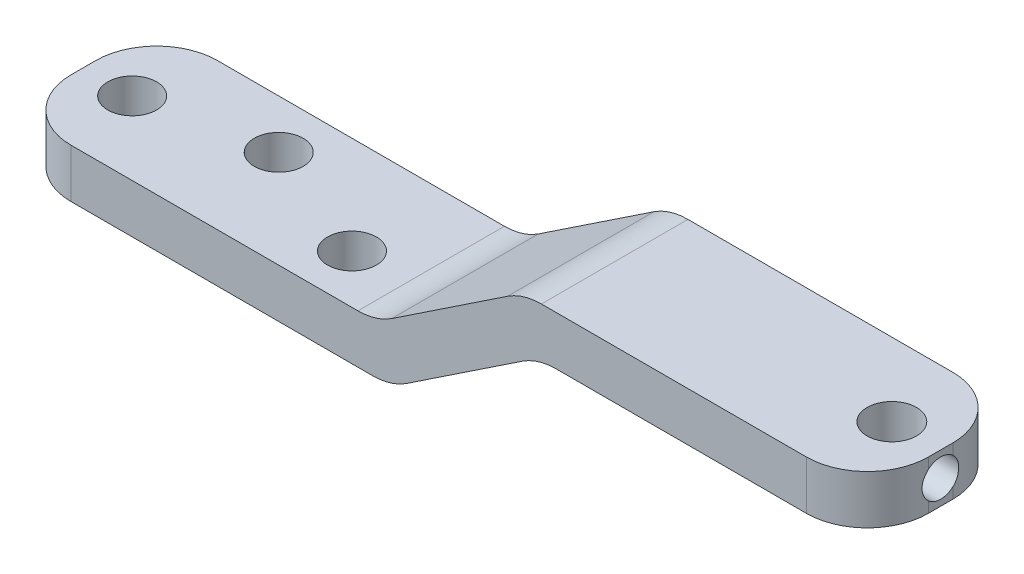
from build123d import *

# Parameters (mm, degrees)
BOSS_EXTRUDE1_DEPTH        = 6
SKETCH2_R                  = 2.025
CUT_EXTRUDE1_DEPTH         = 68.55671766
SKETCH3_R                  = 2
CUT_EXTRUDE2_DEPTH         = 67.962004906
FILLET1_R                  = 5
M3X0_5_TAPPED_HOLE1_REACH  = 72.92
M3X0_5_TAPPED_HOLE1_BORE_R = 1.5


with BuildPart() as part:
    # Sketch1 → Boss-Extrude1 (new, symmetric)
    with BuildSketch(Plane.XY):
        Polygon((4, 0), (-23, 0), (-35, -8), (-66.211102551, -8), (-66.211102551, -4), (-36.211102551, -4), (-24.211102551, 4), (4, 4), align=None)
    extrude(amount=BOSS_EXTRUDE1_DEPTH, both=True)

    # Sketch2 → Cut-Extrude1 (cut, through all)
    with BuildSketch(Plane(origin=(0, 4, 0), x_dir=(1, 0, 0), z_dir=(0, 1, 0))):
        with Locations(Location((0, 0, 0), (0, 0, 180))):
            Circle(SKETCH2_R)
    extrude(amount=-CUT_EXTRUDE1_DEPTH, mode=Mode.SUBTRACT)

    # Sketch3 → Cut-Extrude2 (cut, through all)
    with BuildSketch(Plane(origin=(0, -4, 0), x_dir=(1, 0, 0), z_dir=(0, 1, 0))):
        with Locations(Location((-62.211102551, 0, 0), (0, 0, 270))):
            Circle(SKETCH3_R)
        with Locations(Location((-52.211102551, 2, 0), (0, 0, 270))):
            Circle(SKETCH3_R)
        with Locations(Location((-42.211102551, -2, 0), (0, 0, 270))):
            Circle(SKETCH3_R)
    extrude(amount=-CUT_EXTRUDE2_DEPTH, mode=Mode.SUBTRACT)

    # Fillet1
    fillet1_edges = [part.edges().sort_by_distance(p)[0] for p in [
        (4, 2, -6),
        (-23, 0, 0),
        (-35, -8, 0),
        (-36.211102551, -4, 0),
        (-24.211102551, 4, 0),
        (-66.211102551, -6, 6),
        (4, 2, 6),
        (-66.211102551, -6, -6),
    ]]
    fillet(fillet1_edges, radius=FILLET1_R)

    # M3x0.5 Tapped Hole1 bore → M3x0.5 Tapped Hole1 (cut, up to next)
    with BuildSketch(Plane(origin=(4, 0, 0), x_dir=(0, 0, -1), z_dir=(1, 0, 0)), mode=Mode.PRIVATE) as m3x0_5_tapped_hole1_sk1:
        with Locations((0, 2)):
            Circle(M3X0_5_TAPPED_HOLE1_BORE_R)
    m3x0_5_tapped_hole1_tool1 = extrude(m3x0_5_tapped_hole1_sk1.sketch, amount=-M3X0_5_TAPPED_HOLE1_REACH, mode=Mode.PRIVATE) & part.part
    add(m3x0_5_tapped_hole1_tool1.solids().sort_by_distance((4, 2, 0))[0], mode=Mode.SUBTRACT)


solid = part.part
